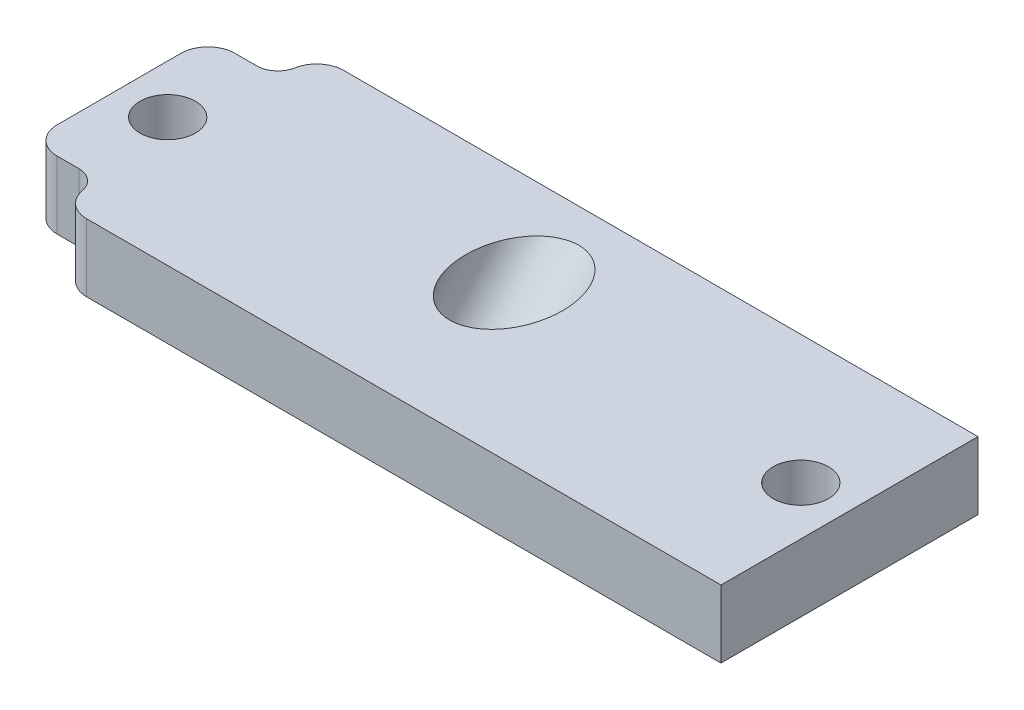
from build123d import *

# Parameters (mm, degrees)
SKETCH2_W                      = 68.58
SKETCH2_H                      = 24.13
SKETCH2_R                      = 2.6
BOSS_EXTRUDE1_DEPTH            = 6.35
CUT_EXTRUDE1_DEPTH             = 7.35
FILLET3_R                      = 2.54
CUT_EXTRUDE2_REACH             = 12.372
SKETCH7_R                      = 4.55
CUT_EXTRUDE2_DIRECTION_2_REACH = 12.372


with BuildPart() as part:
    # Sketch2 → Boss-Extrude1 (new body)
    with BuildSketch(Plane(origin=(0, 0, 0), x_dir=(1, 0, 0), z_dir=(0, 1, 0))):
        with Locations((34.29, 12.065)):
            Rectangle(SKETCH2_W, SKETCH2_H)
        with Locations((4.57, 12.065)):
            Circle(SKETCH2_R, mode=Mode.SUBTRACT)
        with Locations((64.01, 12.065)):
            Circle(SKETCH2_R, mode=Mode.SUBTRACT)
    extrude(amount=BOSS_EXTRUDE1_DEPTH)

    # Sketch3 → Cut-Extrude1 (cut, through all)
    with BuildSketch(Plane(origin=(0, 6.35, 0), x_dir=(1, 0, 0), z_dir=(0, 1, 0))):
        with BuildLine():
            Line((4.57, 3.715), (0, 3.715))
            Line((0, 3.715), (0, 0))
            Line((0, 0), (6.57, 0))
            Line((6.57, 0), (6.57, 1.715))
            ThreePointArc((6.57, 1.715), (5.984213562, 3.129213562), (4.57, 3.715))
        make_face()
        with BuildLine():
            ThreePointArc((4.57, 20.415), (5.984213562, 21.000786438), (6.57, 22.415))
            Line((6.57, 22.415), (6.57, 24.13))
            Line((6.57, 24.13), (0, 24.13))
            Line((0, 24.13), (0, 20.415))
            Line((0, 20.415), (4.57, 20.415))
        make_face()
    extrude(amount=-CUT_EXTRUDE1_DEPTH, mode=Mode.SUBTRACT)

    # Fillet3
    fillet3_edges = [part.edges().sort_by_distance(p)[0] for p in [
        (6.57, 3.175, 0),
        (0, 3.175, -3.715),
        (0, 3.175, -20.415),
        (6.57, 3.175, -24.13),
    ]]
    fillet(fillet3_edges, radius=FILLET3_R)

    # Sketch7 → Cut-Extrude2 (cut, up to next)
    with BuildSketch(Plane(origin=(0, 7.768502242, -6.872990202), x_dir=(-1, 0, 0), z_dir=(0, -0.748955721, 0.662620048)), mode=Mode.PRIVATE) as cut_extrude2_sk1:
        with Locations((-34.29, 6.932332118)):
            Circle(SKETCH7_R)
    cut_extrude2_tool1 = extrude(cut_extrude2_sk1.sketch, amount=-CUT_EXTRUDE2_REACH, mode=Mode.PRIVATE) & part.part
    add(cut_extrude2_tool1.solids().sort_by_distance((34.29, 3.175, -12.065))[0], mode=Mode.SUBTRACT)

    # Sketch7 → Cut-Extrude2 direction 2 (cut, up to next)
    with BuildSketch(Plane(origin=(0, 7.768502242, -6.872990202), x_dir=(-1, 0, 0), z_dir=(0, -0.748955721, 0.662620048)), mode=Mode.PRIVATE) as cut_extrude2_direction_2_sk1:
        with Locations((-34.29, 6.932332118)):
            Circle(SKETCH7_R)
    cut_extrude2_direction_2_tool1 = extrude(cut_extrude2_direction_2_sk1.sketch, amount=CUT_EXTRUDE2_DIRECTION_2_REACH, mode=Mode.PRIVATE) & part.part
    add(cut_extrude2_direction_2_tool1.solids().sort_by_distance((34.29, 3.175, -12.065))[0], mode=Mode.SUBTRACT)


solid = part.part
